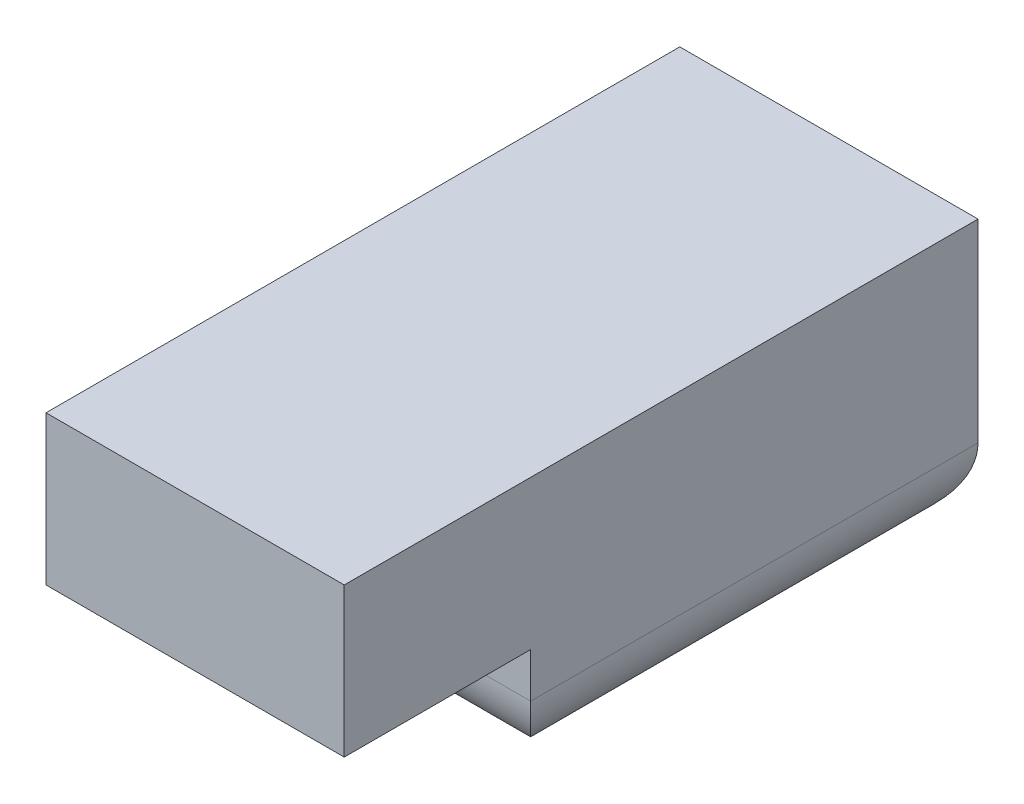
from build123d import *

# Parameters (mm, degrees)
SKETCH2_W           = 4
SKETCH2_H           = 8.5
BOSS_EXTRUDE1_DEPTH = 2
SKETCH3_W           = 4
SKETCH3_H           = 6
BOSS_EXTRUDE2_DEPTH = 1.6
FILLET1_R           = 1


with BuildPart() as part:
    # Sketch2 → Boss-Extrude1 (new body)
    with BuildSketch(Plane(origin=(0, 0, 0), x_dir=(1, 0, 0), z_dir=(0, 1, 0))):
        Rectangle(SKETCH2_W, SKETCH2_H)
    extrude(amount=BOSS_EXTRUDE1_DEPTH)

    # Sketch3 → Boss-Extrude2 (add)
    with BuildSketch(Plane.XZ):
        with Locations((0, -1.25)):
            Rectangle(SKETCH3_W, SKETCH3_H)
    extrude(amount=BOSS_EXTRUDE2_DEPTH)

    # Fillet1
    fillet1_edges = [part.edges().sort_by_distance(p)[0] for p in [
        (-2, -1.6, -1.25),
        (0, -1.6, -4.25),
        (2, -1.6, -1.25),
        (0, -1.6, 1.75),
    ]]
    fillet(fillet1_edges, radius=FILLET1_R)


solid = part.part
